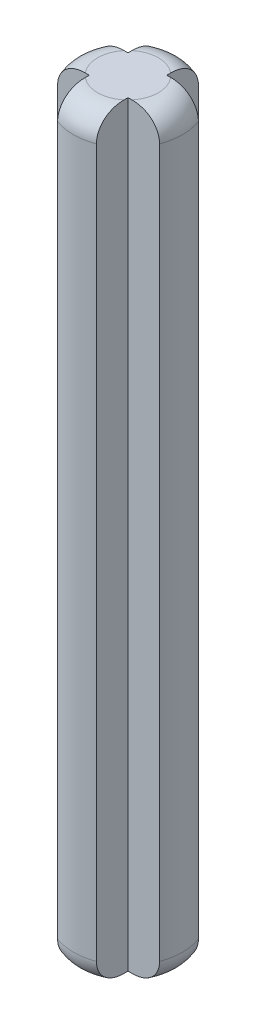
from build123d import *

# Parameters (mm, degrees)
BOSS_EXTRUDE1_DEPTH = 31.2
FILLET1_R           = 1
FILLET2_R           = 1
FILLET3_R           = 1
FILLET4_R           = 1
FILLET20_R          = 1
FILLET21_R          = 1
FILLET22_R          = 1
FILLET23_R          = 1


with BuildPart() as part:
    # Sketch1 → Boss-Extrude1 (new body)
    with BuildSketch(Plane(origin=(0, 0, 0), x_dir=(1, 0, 0), z_dir=(0, 1, 0))):
        with BuildLine():
            Line((-0.8, -0.8), (-0.8, -2.102974084))
            ThreePointArc((-0.8, -2.102974084), (0, -2.25), (0.8, -2.102974084))
            Line((0.8, -2.102974084), (0.8, -0.8))
            Line((0.8, -0.8), (2.102974084, -0.8))
            ThreePointArc((2.102974084, -0.8), (2.25, 0), (2.102974084, 0.8))
            Line((2.102974084, 0.8), (0.8, 0.8))
            Line((0.8, 0.8), (0.8, 2.102974084))
            ThreePointArc((0.8, 2.102974084), (0, 2.25), (-0.8, 2.102974084))
            Line((-0.8, 2.102974084), (-0.8, 0.8))
            Line((-0.8, 0.8), (-2.102974084, 0.8))
            ThreePointArc((-2.102974084, 0.8), (-2.25, 0), (-2.102974084, -0.8))
            Line((-2.102974084, -0.8), (-0.8, -0.8))
        make_face()
    extrude(amount=BOSS_EXTRUDE1_DEPTH)

    # Fillet1
    fillet1_edges = [part.edges().sort_by_distance(p)[0] for p in [
        (-2.25, 0, 0),
    ]]
    fillet(fillet1_edges, radius=FILLET1_R)

    # Fillet2
    fillet2_edges = [part.edges().sort_by_distance(p)[0] for p in [
        (0, 0, 2.25),
    ]]
    fillet(fillet2_edges, radius=FILLET2_R)

    # Fillet3
    fillet3_edges = [part.edges().sort_by_distance(p)[0] for p in [
        (2.25, 0, 0),
    ]]
    fillet(fillet3_edges, radius=FILLET3_R)

    # Fillet4
    fillet4_edges = [part.edges().sort_by_distance(p)[0] for p in [
        (0, 0, -2.25),
    ]]
    fillet(fillet4_edges, radius=FILLET4_R)

    # Fillet20
    fillet20_edges = [part.edges().sort_by_distance(p)[0] for p in [
        (2.25, 31.2, 0),
    ]]
    fillet(fillet20_edges, radius=FILLET20_R)

    # Fillet21
    fillet21_edges = [part.edges().sort_by_distance(p)[0] for p in [
        (0, 31.2, 2.25),
    ]]
    fillet(fillet21_edges, radius=FILLET21_R)

    # Fillet22
    fillet22_edges = [part.edges().sort_by_distance(p)[0] for p in [
        (-2.25, 31.2, 0),
    ]]
    fillet(fillet22_edges, radius=FILLET22_R)

    # Fillet23
    fillet23_edges = [part.edges().sort_by_distance(p)[0] for p in [
        (0, 31.2, -2.25),
    ]]
    fillet(fillet23_edges, radius=FILLET23_R)


solid = part.part
